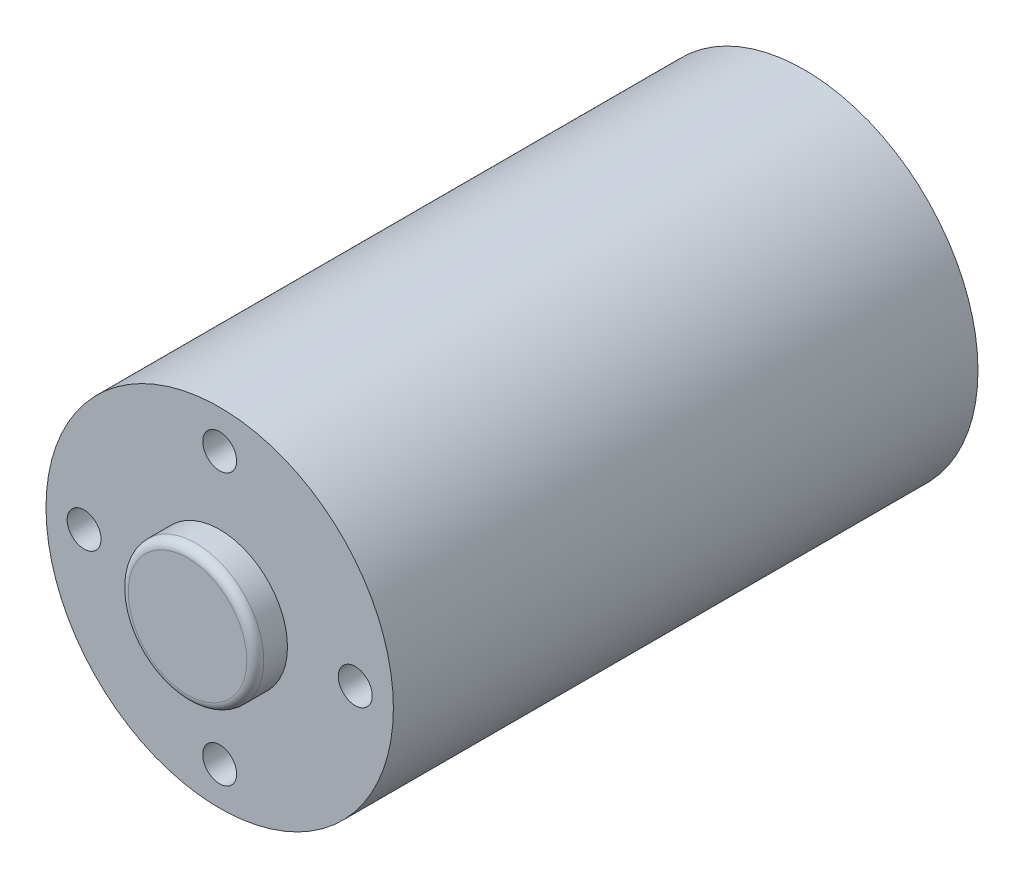
from build123d import *

# Parameters (mm, degrees)
BOSS_EXTRUDE1_DEPTH      = 19
BOSS_EXTRUDE1_DEPTH_BACK = 19
SKETCH1_R                = 10.25
SKETCH2_R                = 4
BOSS_EXTRUDE2_DEPTH      = 1.9
BOSS_EXTRUDE3_START      = 1
SKETCH3_R                = 4
BOSS_EXTRUDE3_DEPTH      = 1
SKETCH4_R                = 1
CUT_EXTRUDE1_DEPTH       = 3.5
FILLET1_R                = 0.5
CUT_EXTRUDE3_DEPTH       = 5.5
CUT_EXTRUDE3_DEPTH_BACK  = 3.5
SKETCH7_R                = 10.25
SKETCH9_R                = 1.5
CUT_EXTRUDE5_DEPTH       = 5


with BuildPart() as part:
    # Sketch1 → Boss-Extrude1 (new, two sides: drawn at the far end of the back side and taken through both)
    with BuildSketch(Plane.XY.offset(-BOSS_EXTRUDE1_DEPTH_BACK)):
        Circle(SKETCH1_R)
    extrude(amount=BOSS_EXTRUDE1_DEPTH + BOSS_EXTRUDE1_DEPTH_BACK)

    # Sketch2 → Boss-Extrude2 (add)
    with BuildSketch(Plane.XY.offset(19)):
        Circle(SKETCH2_R)
    extrude(amount=BOSS_EXTRUDE2_DEPTH)

    # Sketch3 → Boss-Extrude3 (add)
    with BuildSketch(Plane(origin=(0, 0, -19), x_dir=(-1, 0, 0), z_dir=(0, 0, -1)).offset(BOSS_EXTRUDE3_START)):
        Circle(SKETCH3_R)
    extrude(amount=-BOSS_EXTRUDE3_DEPTH)

    # Sketch4 → Cut-Extrude1 (cut)
    with BuildSketch(Plane.XY.offset(19)):
        with Locations((8, 0)):
            Circle(SKETCH4_R)
        with Locations((0, 8)):
            Circle(SKETCH4_R)
        with Locations((0, -8)):
            Circle(SKETCH4_R)
        with Locations((-8, 0)):
            Circle(SKETCH4_R)
    cut_extrude1 = extrude(amount=-CUT_EXTRUDE1_DEPTH, mode=Mode.SUBTRACT)

    # Fillet1
    fillet1_edges = [part.edges().sort_by_distance(p)[0] for p in [
        (-4, 0, 20.9),
    ]]
    fillet(fillet1_edges, radius=FILLET1_R)

    # Mirror1: Cut-Extrude1 across plane
    add(cut_extrude1.mirror(Plane(origin=(0, 0, 0), x_dir=(1, 0, 0), z_dir=(0, 0, -1))), mode=Mode.SUBTRACT)

    # Sketch7 → Cut-Extrude3 (cut, two sides: drawn at the far end of the back side and taken through both)
    with BuildSketch(Plane(origin=(0, 0, -19), x_dir=(-1, 0, 0), z_dir=(0, 0, -1)).offset(-CUT_EXTRUDE3_DEPTH_BACK)):
        Circle(SKETCH7_R)
    extrude(amount=CUT_EXTRUDE3_DEPTH + CUT_EXTRUDE3_DEPTH_BACK, mode=Mode.SUBTRACT)

    # Sketch9 → Cut-Extrude5 (cut)
    with BuildSketch(Plane(origin=(0, 0, -15.5), x_dir=(-1, 0, 0), z_dir=(0, 0, -1))):
        Circle(SKETCH9_R)
    extrude(amount=-CUT_EXTRUDE5_DEPTH, mode=Mode.SUBTRACT)


solid = part.part
